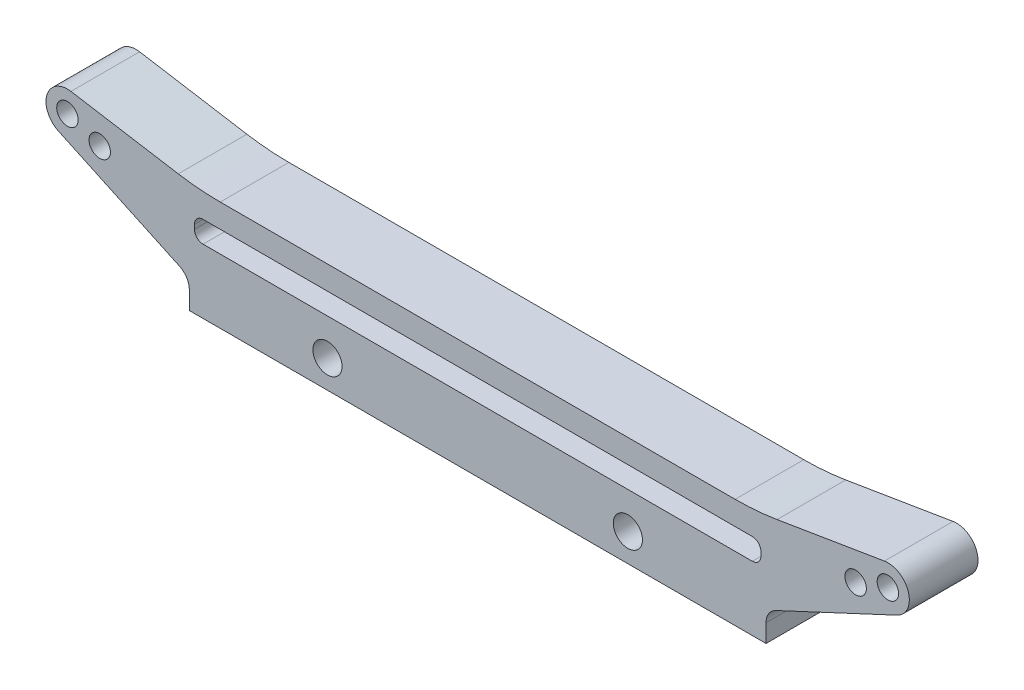
from build123d import *

# Parameters (mm, degrees)
SKETCH1_R             = 0.5
BOSS_EXTRUDE1_DEPTH   = 8
M3_CLEARANCE_HOLE1_D  = 3.4
M3X0_5_TAPPED_HOLE1_D = 2.5
SKETCH6_W             = 67.2
SKETCH6_H             = 8
CUT_EXTRUDE1_DEPTH    = 0.25


with BuildPart() as part:
    # Sketch1 → Boss-Extrude1 (new body)
    with BuildSketch(Plane.XY):
        with BuildLine():
            Line((-33.6, 0), (33.6, 0))
            Line((33.6, 0), (33.6, 2.345845935))
            ThreePointArc((33.6, 2.345845935), (33.913217108, 3.420445152), (34.754763477, 4.158461509))
            Line((34.754763477, 4.158461509), (48.856545654, 10.734230532))
            ThreePointArc((48.856545654, 10.734230532), (50.188323304, 13.73885844), (47.392535439, 15.466571027))
            Line((47.392535439, 15.466571027), (34.889574734, 13.401147676))
            ThreePointArc((34.889574734, 13.401147676), (32.45300125, 13.100455106), (30, 13))
            Line((30, 13), (-30, 13))
            ThreePointArc((-30, 13), (-32.45300125, 13.100455106), (-34.889574734, 13.401147676))
            Line((-34.889574734, 13.401147676), (-47.392535439, 15.466571027))
            ThreePointArc((-47.392535439, 15.466571027), (-50.188323304, 13.73885844), (-48.856545654, 10.734230532))
            Line((-48.856545654, 10.734230532), (-34.754763477, 4.158461509))
            ThreePointArc((-34.754763477, 4.158461509), (-33.913217108, 3.420445152), (-33.6, 2.345845935))
            Line((-33.6, 2.345845935), (-33.6, 0))
        make_face()
        with Locations((-47.8, 13)):
            Circle(SKETCH1_R, mode=Mode.SUBTRACT)
        with Locations((47.8, 13)):
            Circle(SKETCH1_R, mode=Mode.SUBTRACT)
        with Locations((-44.041229517, 11.631919427)):
            Circle(SKETCH1_R, mode=Mode.SUBTRACT)
        with Locations((44.041229517, 11.631919427)):
            Circle(SKETCH1_R, mode=Mode.SUBTRACT)
        with BuildLine():
            Line((33, 8.75), (33, 9.25))
            ThreePointArc((33, 9.25), (32.707106781, 9.957106781), (32, 10.25))
            Line((32, 10.25), (-32, 10.25))
            ThreePointArc((-32, 10.25), (-32.707106781, 9.957106781), (-33, 9.25))
            Line((-33, 9.25), (-33, 8.75))
            ThreePointArc((-33, 8.75), (-32.707106781, 8.042893219), (-32, 7.75))
            Line((-32, 7.75), (32, 7.75))
            ThreePointArc((32, 7.75), (32.707106781, 8.042893219), (33, 8.75))
        make_face(mode=Mode.SUBTRACT)
    extrude(amount=BOSS_EXTRUDE1_DEPTH)

    # M3 Clearance Hole1 (through all)
    with Locations(Plane.XY.offset(8)):
        with Locations((-17.5, 3.5), (17.5, 3.5)):
            Hole(M3_CLEARANCE_HOLE1_D / 2)

    # M3x0.5 Tapped Hole1 (through all)
    with Locations(Plane.XY.offset(8)):
        with Locations((-47.8, 13), (47.8, 13), (-44.041229517, 11.631919427), (44.041229517, 11.631919427)):
            Hole(M3X0_5_TAPPED_HOLE1_D / 2)

    # Sketch6 → Cut-Extrude1 (cut)
    with BuildSketch(Plane.XZ):
        with Locations((0, 4)):
            Rectangle(SKETCH6_W, SKETCH6_H)
    extrude(amount=-CUT_EXTRUDE1_DEPTH, mode=Mode.SUBTRACT)


solid = part.part
